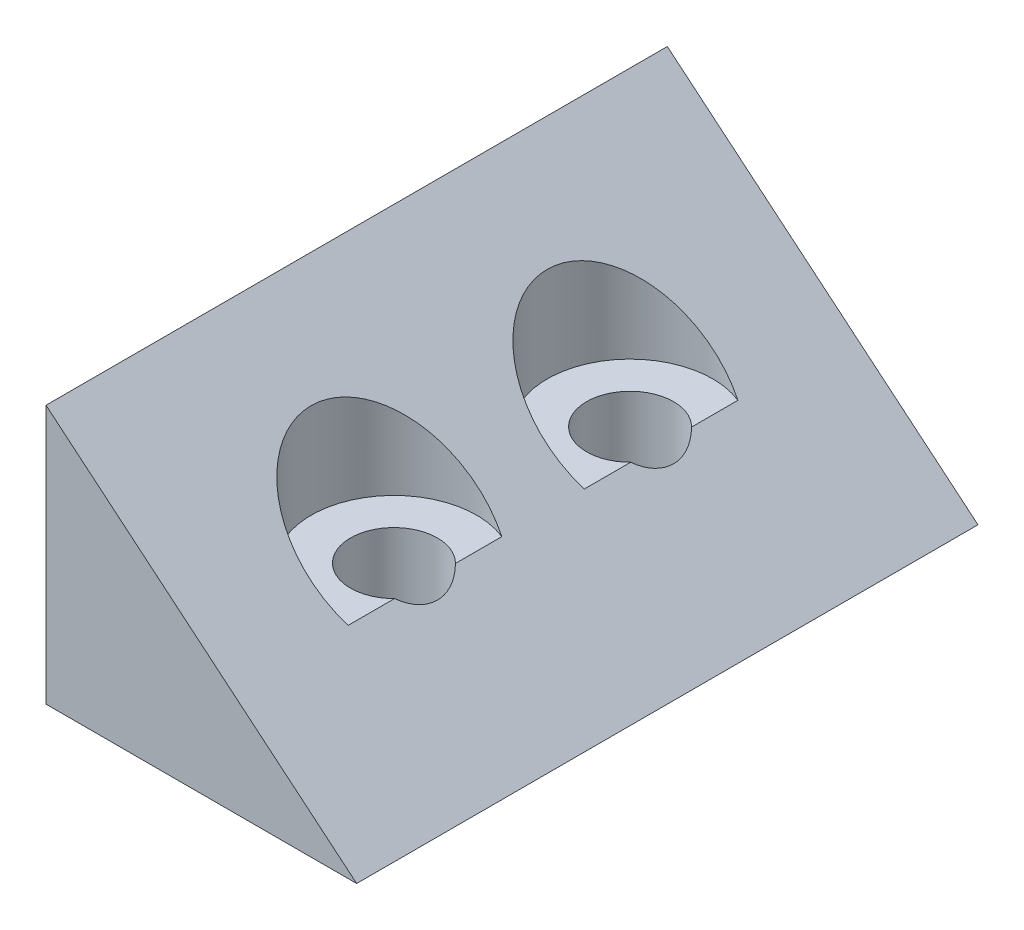
from build123d import *

# Parameters (mm, degrees)
EXTRUDE_1_DEPTH     = 30
SKETCH_2_R          = 2.1
CUT_EXTRUDE_1_DEPTH = 30
CUT_EXTRUDE_START   = -5
SKETCH_3_R          = 4
CUT_EXTRUDE_2_DEPTH = 8.5


with BuildPart() as part:
    # 草圖1 → 填料-伸長1 (new body)
    with BuildSketch(Plane.XY):
        Polygon((0, 0), (15, 0), (0, 12.5), align=None)
    extrude(amount=EXTRUDE_1_DEPTH)

    # 草圖2 → 除料-伸長1 (cut)
    with BuildSketch(Plane(origin=(0, 0, 0), x_dir=(-1, 0, 0), z_dir=(0, -1, 0))):
        with Locations((-7.5, -20.7)):
            Circle(SKETCH_2_R)
        with Locations((-7.5, -9.3)):
            Circle(SKETCH_2_R)
    extrude(amount=-CUT_EXTRUDE_1_DEPTH, mode=Mode.SUBTRACT)

    # 草圖3 → 除料-伸長2 (cut, through all)
    with BuildSketch(Plane.XZ.offset(CUT_EXTRUDE_START)):
        with Locations((7.5, 20.7)):
            Circle(SKETCH_3_R)
        with Locations((7.5, 9.3)):
            Circle(SKETCH_3_R)
    extrude(amount=-CUT_EXTRUDE_2_DEPTH, mode=Mode.SUBTRACT)


solid = part.part
